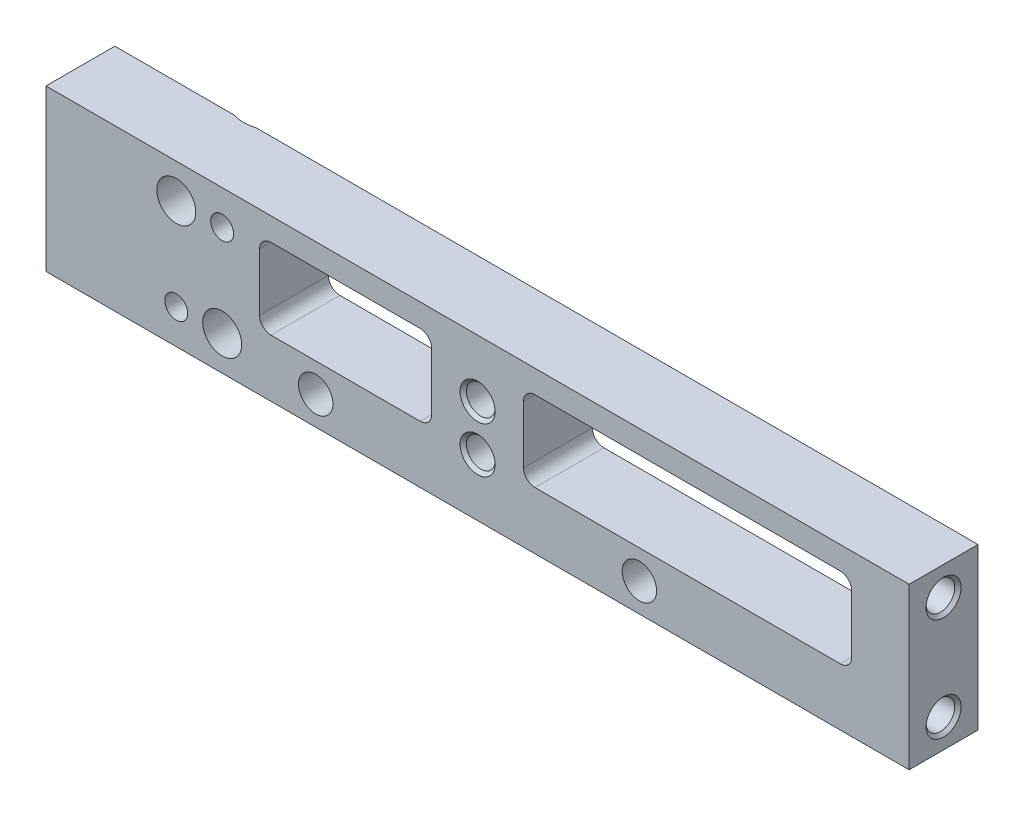
from build123d import *

# Parameters (mm, degrees)
SKETCH1_W                                       = 75.2
SKETCH1_H                                       = 14
BOSS_EXTRUDE1_DEPTH                             = 6
SKETCH2_W                                       = 15
SKETCH2_H                                       = 7
SKETCH2_W_2                                     = 28.6
CUT_EXTRUDE1_DEPTH                              = 7
FILLET1_R                                       = 1
F_3_0_3_DIAMETER_HOLE1_D                        = 3
F_3_0_3_DIAMETER_HOLE1_DEPTH                    = 45
F_3_0_3_DIAMETER_HOLE1_TIP                      = 0.901290929
CSK_FOR_M3_FLAT_HEAD_MACHINE_SCREW1_D           = 3.4
CSK_FOR_M3_FLAT_HEAD_MACHINE_SCREW1_CSINK_D     = 6.3
CSK_FOR_M3_FLAT_HEAD_MACHINE_SCREW1_CSINK_ANGLE = 90
F_2_0_2_DIAMETER_HOLE1_D                        = 2
M3X0_5_TAPPED_HOLE1_AT_2_COUNT                  = 2
M3X0_5_TAPPED_HOLE1_AT_2_PITCH                  = 9
M3X0_5_TAPPED_HOLE2_D                           = 2.5
M3X0_5_TAPPED_HOLE2_CSINK_D                     = 3.05
M3X0_5_TAPPED_HOLE2_CSINK_ANGLE                 = 90


with BuildPart() as part:
    # Sketch1 → Boss-Extrude1 (new body)
    with BuildSketch(Plane.XY):
        with Locations((37.6, 7)):
            Rectangle(SKETCH1_W, SKETCH1_H)
    extrude(amount=BOSS_EXTRUDE1_DEPTH)

    # Sketch2 → Cut-Extrude1 (cut, through all)
    with BuildSketch(Plane.XY.offset(6)):
        with Locations((26.1, 8.5)):
            Rectangle(SKETCH2_W, SKETCH2_H)
        with Locations((55.9, 8.5)):
            Rectangle(SKETCH2_W_2, SKETCH2_H)
    extrude(amount=-CUT_EXTRUDE1_DEPTH, mode=Mode.SUBTRACT)

    # Fillet1
    fillet1_edges = [part.edges().sort_by_distance(p)[0] for p in [
        (18.6, 5, 3),
        (18.6, 12, 3),
        (33.6, 12, 3),
        (33.6, 5, 3),
        (41.6, 5, 3),
        (41.6, 12, 3),
        (70.2, 12, 3),
        (70.2, 5, 3),
    ]]
    fillet(fillet1_edges, radius=FILLET1_R)

    # Ø3.0 (3) Diameter Hole1
    with Locations(Plane.XY.offset(6)):
        with Locations((23.5, 2.5), (51.7, 2.5)):
            Hole(F_3_0_3_DIAMETER_HOLE1_D / 2, depth=F_3_0_3_DIAMETER_HOLE1_DEPTH)
            with Locations((0, 0, -(F_3_0_3_DIAMETER_HOLE1_DEPTH + F_3_0_3_DIAMETER_HOLE1_TIP / 2))):  # 118° drill point
                Cone(0, F_3_0_3_DIAMETER_HOLE1_D / 2, F_3_0_3_DIAMETER_HOLE1_TIP, mode=Mode.SUBTRACT)

    # CSK for M3 Flat Head Machine Screw1 (through all)
    with Locations(Plane(origin=(0, 0, 0), x_dir=(-1, 0, 0), z_dir=(0, 0, -1))):
        with Locations((-11.35, 11), (-15.35, 3)):
            CounterSinkHole(CSK_FOR_M3_FLAT_HEAD_MACHINE_SCREW1_D / 2, CSK_FOR_M3_FLAT_HEAD_MACHINE_SCREW1_CSINK_D / 2, counter_sink_angle=CSK_FOR_M3_FLAT_HEAD_MACHINE_SCREW1_CSINK_ANGLE)

    # Ø2.0 (2) Diameter Hole1 (through all)
    with Locations(Plane(origin=(0, 0, 0), x_dir=(-1, 0, 0), z_dir=(0, 0, -1))):
        with Locations((-15.35, 11), (-11.35, 3)):
            Hole(F_2_0_2_DIAMETER_HOLE1_D / 2)

    # Sketch12 → M3x0.5 Tapped Hole1 (revolve, cut)
    with BuildSketch(Plane(origin=(75.2, 11.5, 3), x_dir=(0, 0, -1), z_dir=(0, 1, 0))):
        Polygon((0, 0), (0, 3.751075774), (1.25, 3), (1.25, 0.275), (1.525, 0), align=None)
    m3x0_5_tapped_hole1 = revolve(axis=Axis((81.55, 11.5, 3), (-1, 0, 0)), mode=Mode.SUBTRACT)

    # M3x0.5 Tapped Hole1 at 2: M3x0.5 Tapped Hole1 ×2
    with Locations(*[(0, -i * M3X0_5_TAPPED_HOLE1_AT_2_PITCH, 0) for i in range(1, M3X0_5_TAPPED_HOLE1_AT_2_COUNT)]):
        add(m3x0_5_tapped_hole1, mode=Mode.SUBTRACT)

    # Mirror1: M3x0.5 Tapped Hole1 across plane
    add(m3x0_5_tapped_hole1.mirror(Plane(origin=(37.6, 0, 0), x_dir=(0, 0, 1), z_dir=(1, 0, 0))), mode=Mode.SUBTRACT)

    # Mirror1 copy 1 sketch → Mirror1 copy 1 (revolve, cut)
    with BuildSketch(Plane(origin=(0, 2.5, 3), x_dir=(0, 0, -1), z_dir=(0, 1, 0))):
        Polygon((0, 0), (0, -3.751075774), (1.25, -3), (1.25, -0.275), (1.525, 0), align=None)
    revolve(axis=Axis((-6.35, 2.5, 3), (-1, 0, 0)), mode=Mode.SUBTRACT)

    # M3x0.5 Tapped Hole2 (through all)
    with Locations(Plane.XY.offset(6)):
        with Locations((37.6, 9), (37.6, 5)):
            CounterSinkHole(M3X0_5_TAPPED_HOLE2_D / 2, M3X0_5_TAPPED_HOLE2_CSINK_D / 2, counter_sink_angle=M3X0_5_TAPPED_HOLE2_CSINK_ANGLE)


solid = part.part
